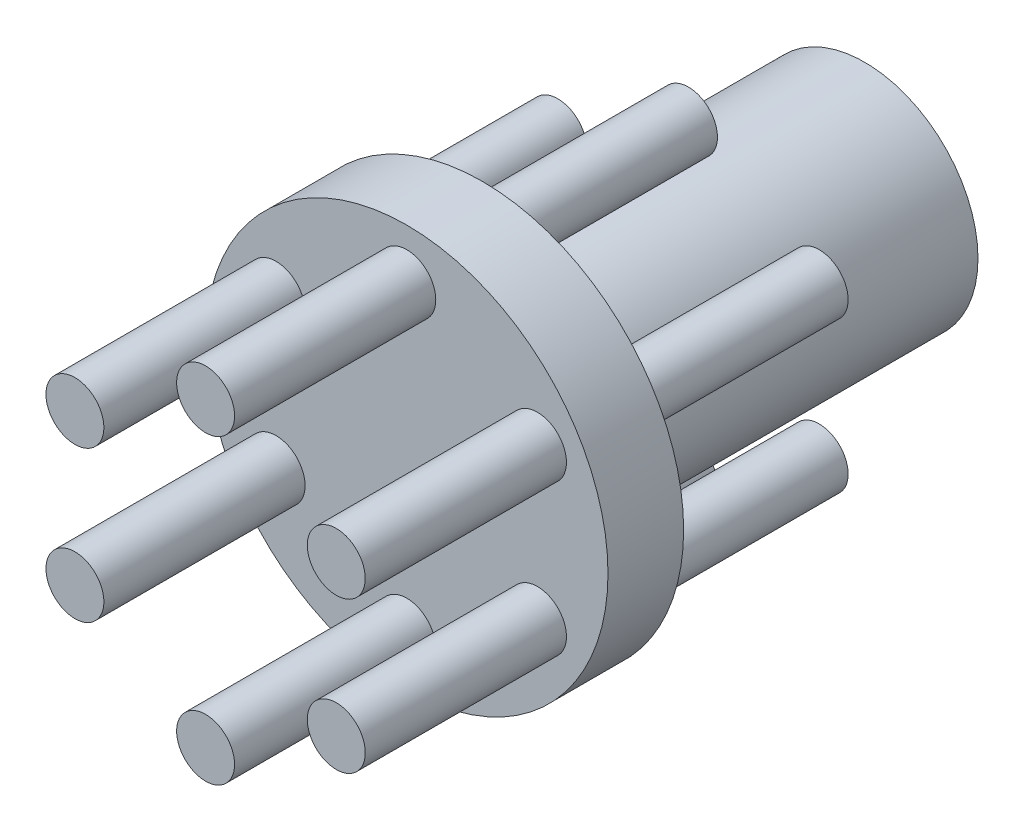
from build123d import *

# Parameters (mm, degrees)
SKETCH1_R                = 12.7
BOSS_EXTRUDE1_DEPTH      = 4.7752
SKETCH2_R                = 7.1501
BOSS_EXTRUDE2_DEPTH      = 24.13
SKETCH3_R                = 1.8288
BOSS_EXTRUDE3_DEPTH      = 12.7
BOSS_EXTRUDE3_DEPTH_BACK = 17.78


with BuildPart() as part:
    # Sketch1 → Boss-Extrude1 (new body)
    with BuildSketch(Plane.XY):
        Circle(SKETCH1_R)
    extrude(amount=BOSS_EXTRUDE1_DEPTH)

    # Sketch2 → Boss-Extrude2 (add)
    with BuildSketch(Plane(origin=(0, 0, 0), x_dir=(-1, 0, 0), z_dir=(0, 0, -1))):
        Circle(SKETCH2_R)
    extrude(amount=BOSS_EXTRUDE2_DEPTH)

    # Sketch3 → Boss-Extrude3 (add, two sides)
    with BuildSketch(Plane.XY.offset(4.7752)) as boss_extrude3_sk:
        with Locations((0, 9.525)):
            Circle(SKETCH3_R)
        with Locations((8.248891971, 4.7625)):
            Circle(SKETCH3_R)
        with Locations((8.248891971, -4.7625)):
            Circle(SKETCH3_R)
        with Locations((0, -9.525)):
            Circle(SKETCH3_R)
        with Locations((-8.248891971, -4.7625)):
            Circle(SKETCH3_R)
        with Locations((-8.248891971, 4.7625)):
            Circle(SKETCH3_R)
    extrude(amount=BOSS_EXTRUDE3_DEPTH)
    extrude(boss_extrude3_sk.sketch, amount=-BOSS_EXTRUDE3_DEPTH_BACK)


solid = part.part
